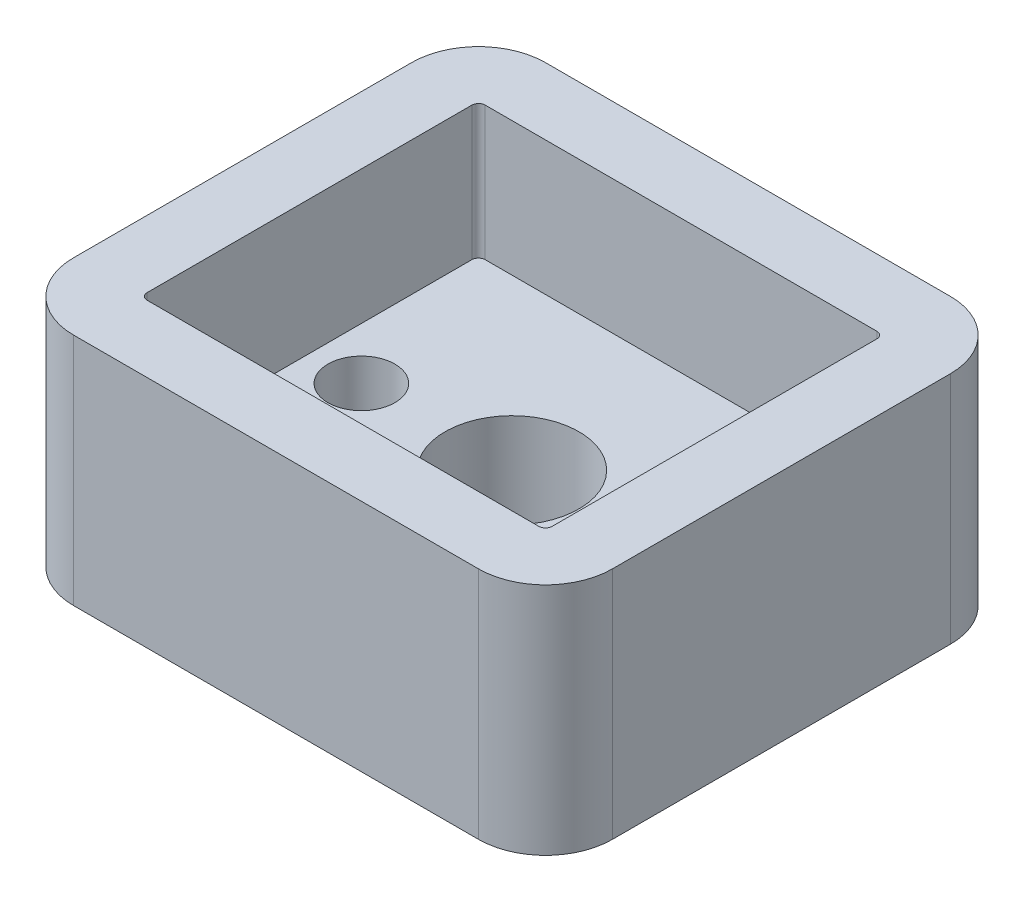
from build123d import *

# Parameters (mm, degrees)
SKETCH1_W                                            = 16.1
SKETCH1_H                                            = 14.1
BOSS_EXTRUDE1_DEPTH                                  = 7
SKETCH3_W                                            = 12.1
SKETCH3_H                                            = 10.1
CUT_EXTRUDE1_DEPTH                                   = 4
CSK_FOR_M1_6_COUNTERSUNK_FLAT_HEAD_SCREW_D           = 2
CSK_FOR_M1_6_COUNTERSUNK_FLAT_HEAD_SCREW_DEPTH       = 3
CSK_FOR_M1_6_COUNTERSUNK_FLAT_HEAD_SCREW_CSINK_D     = 4
CSK_FOR_M1_6_COUNTERSUNK_FLAT_HEAD_SCREW_CSINK_ANGLE = 90
SKETCH8_R                                            = 2
CUT_EXTRUDE2_DEPTH                                   = 4
FILLET1_R                                            = 2
FILLET2_R                                            = 0.2


with BuildPart() as part:
    # Sketch1 → Boss-Extrude1 (new body)
    with BuildSketch(Plane(origin=(0, 0, 0), x_dir=(1, 0, 0), z_dir=(0, 1, 0))):
        Rectangle(SKETCH1_W, SKETCH1_H)
    extrude(amount=BOSS_EXTRUDE1_DEPTH)

    # Sketch3 → Cut-Extrude1 (cut)
    with BuildSketch(Plane(origin=(0, 7, 0), x_dir=(1, 0, 0), z_dir=(0, 1, 0))):
        Rectangle(SKETCH3_W, SKETCH3_H)
    extrude(amount=-CUT_EXTRUDE1_DEPTH, mode=Mode.SUBTRACT)

    # CSK for M1.6 Countersunk Flat Head Screw1
    with Locations(Plane(origin=(0, 0, 0), x_dir=(-1, 0, 0), z_dir=(0, -1, 0))):
        with Locations((4.5, 0), (-4.5, 0)):
            CounterSinkHole(CSK_FOR_M1_6_COUNTERSUNK_FLAT_HEAD_SCREW_D / 2, CSK_FOR_M1_6_COUNTERSUNK_FLAT_HEAD_SCREW_CSINK_D / 2, depth=CSK_FOR_M1_6_COUNTERSUNK_FLAT_HEAD_SCREW_DEPTH, counter_sink_angle=CSK_FOR_M1_6_COUNTERSUNK_FLAT_HEAD_SCREW_CSINK_ANGLE)

    # Sketch8 → Cut-Extrude2 (cut, through all)
    with BuildSketch(Plane(origin=(0, 3, 0), x_dir=(1, 0, 0), z_dir=(0, 1, 0))):
        Circle(SKETCH8_R)
    extrude(amount=-CUT_EXTRUDE2_DEPTH, mode=Mode.SUBTRACT)

    # Fillet1
    fillet1_edges = [part.edges().sort_by_distance(p)[0] for p in [
        (-8.05, 3.5, -7.05),
        (8.05, 3.5, -7.05),
        (8.05, 3.5, 7.05),
        (-8.05, 3.5, 7.05),
    ]]
    fillet(fillet1_edges, radius=FILLET1_R)

    # Fillet2
    fillet2_edges = [part.edges().sort_by_distance(p)[0] for p in [
        (-6.05, 5, 5.05),
        (-6.05, 5, -5.05),
        (6.05, 5, -5.05),
        (6.05, 5, 5.05),
    ]]
    fillet(fillet2_edges, radius=FILLET2_R)


solid = part.part
